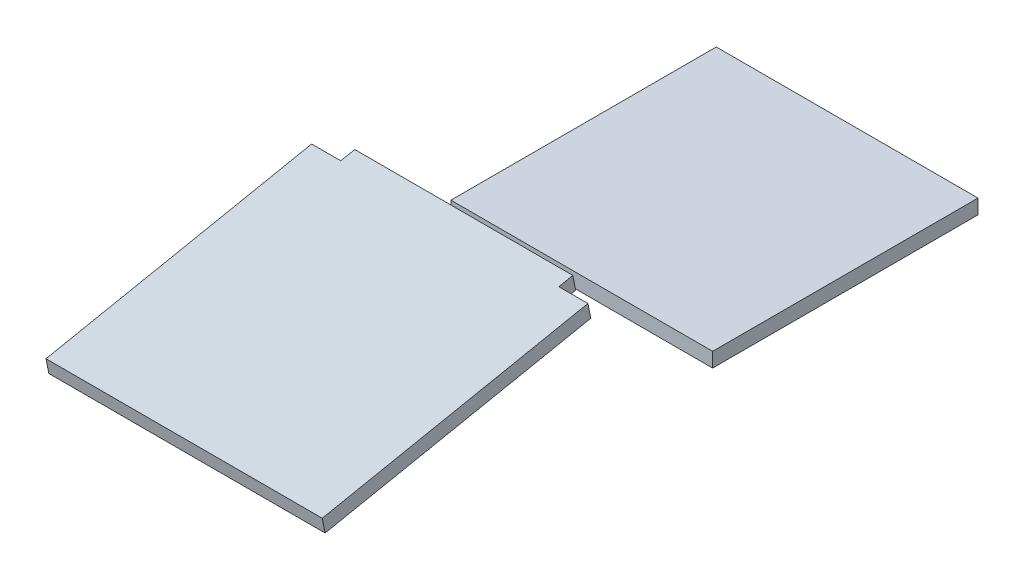
from build123d import *

# Parameters (mm, degrees)
SKETCH3_W           = 457.2
SKETCH3_H           = 463.55
BOSS_EXTRUDE1_DEPTH = 25.4
BOSS_EXTRUDE2_DEPTH = 25.4


with BuildPart() as part:
    # Sketch3 → Boss-Extrude1 (new body)
    with BuildSketch(Plane(origin=(0, 69.85, 0), x_dir=(1, 0, 0), z_dir=(0, 1, 0))):
        Rectangle(SKETCH3_W, SKETCH3_H)
    extrude(amount=-BOSS_EXTRUDE1_DEPTH)


with BuildPart() as body_2:
    # Sketch4 → Boss-Extrude2 (new body)
    with BuildSketch(Plane(origin=(0, 342.533653846, 68.506730769), x_dir=(0, 0.196116135, -0.980580676), z_dir=(0, -0.980580676, -0.196116135))):
        Polygon((-874.849564335, 190.5), (-874.849564335, 241.3), (-401.621330246, 241.3), (-401.621330246, 190.5), (-376.714581084, 190.5), (-376.714581084, -190.5), (-401.621330246, -190.5), (-401.621330246, -241.3), (-874.849564335, -241.3), (-874.849564335, -190.5), align=None)
    extrude(amount=BOSS_EXTRUDE2_DEPTH)


solid = Compound([part.part, body_2.part])
